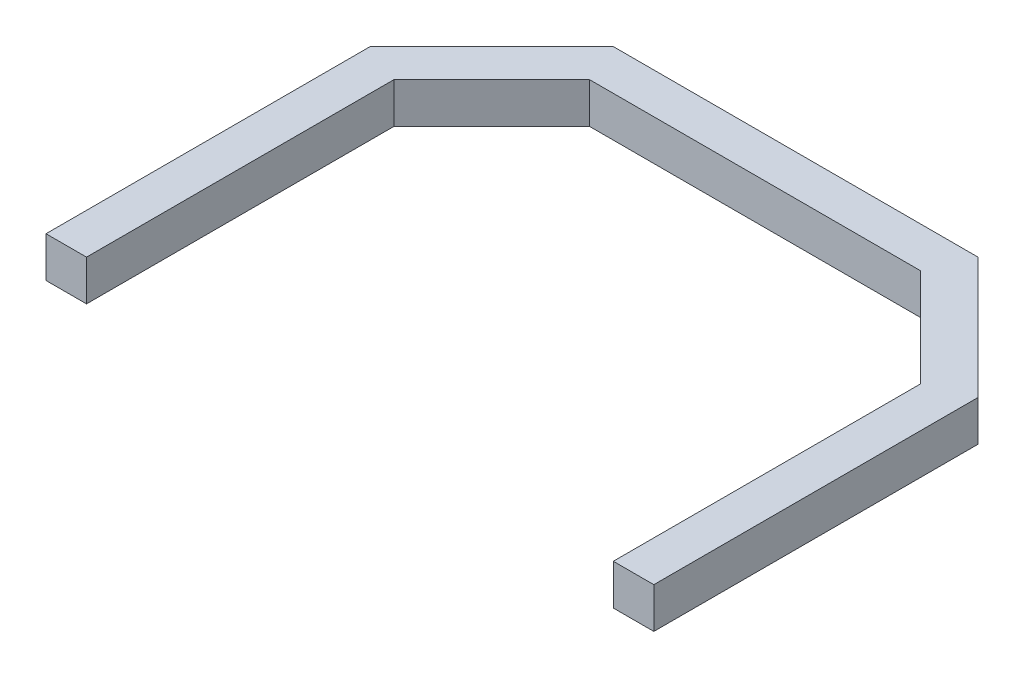
from build123d import *

# Parameters (mm, degrees)
BOSS_EXTRUDE1_DEPTH = 5


with BuildPart() as part:
    # Sketch1 → Boss-Extrude1 (new body)
    with BuildSketch(Plane(origin=(0, 0, 0), x_dir=(1, 0, 0), z_dir=(0, 1, 0))):
        Polygon((-39.015250545, -6.05664488), (-24.015250545, 8.94335512), (20.984749455, 8.94335512), (35.984749455, -6.05664488), (35.984749455, -46.05664488), (30.984749455, -46.05664488), (30.984749455, -8.127712692), (18.913681643, 3.94335512), (-21.944182733, 3.94335512), (-34.015250545, -8.127712692), (-34.015250545, -46.05664488), (-39.015250545, -46.05664488), align=None)
    extrude(amount=BOSS_EXTRUDE1_DEPTH)


solid = part.part
